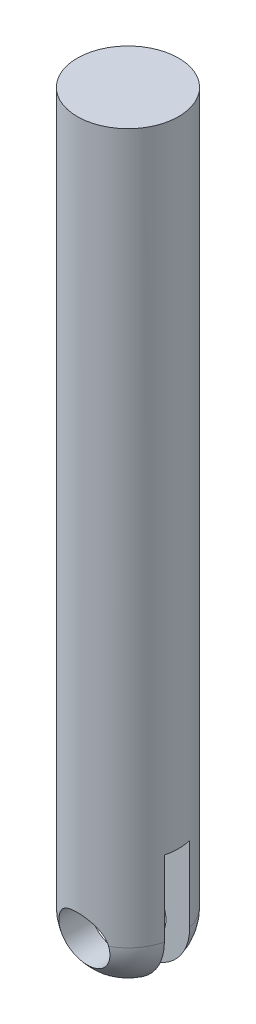
from build123d import *

# Parameters (mm, degrees)
SKETCH2_W               = 5
SKETCH2_H               = 33.382597824
CUT_EXTRUDE1_DEPTH      = 11
CUT_EXTRUDE1_DEPTH_BACK = 11
SKETCH3_R               = 5
CUT_EXTRUDE2_DEPTH      = 13.5
CUT_EXTRUDE2_DEPTH_BACK = 8.5


with BuildPart() as part:
    # Sketch1 → Revolve1 (revolve)
    with BuildSketch(Plane(origin=(0, 0, 2.5), x_dir=(-1, 0, 0), z_dir=(0, 0, -1))):
        with BuildLine():
            Line((0, 233.5), (0, 83.5))
            ThreePointArc((0, 83.5), (7.071067812, 86.428932188), (10, 93.5))
            Line((10, 93.5), (10, 233.5))
            Line((10, 233.5), (0, 233.5))
        make_face()
    revolve(axis=Axis((0, 233.5, 2.5), (0, -1, 0)))

    # Sketch2 → Cut-Extrude1 (cut, two sides)
    with BuildSketch(Plane(origin=(0, 0, 0), x_dir=(0, 0, -1), z_dir=(1, 0, 0))) as cut_extrude1_sk:
        with Locations((-2.5, 91.70929716)):
            Rectangle(SKETCH2_W, SKETCH2_H)
    extrude(amount=CUT_EXTRUDE1_DEPTH, mode=Mode.SUBTRACT)
    extrude(cut_extrude1_sk.sketch, amount=-CUT_EXTRUDE1_DEPTH_BACK, mode=Mode.SUBTRACT)

    # Sketch3 → Cut-Extrude2 (cut, two sides)
    with BuildSketch(Plane.XY) as cut_extrude2_sk:
        with Locations((0, 92.5)):
            Circle(SKETCH3_R)
    extrude(amount=CUT_EXTRUDE2_DEPTH, mode=Mode.SUBTRACT)
    extrude(cut_extrude2_sk.sketch, amount=-CUT_EXTRUDE2_DEPTH_BACK, mode=Mode.SUBTRACT)


solid = part.part
